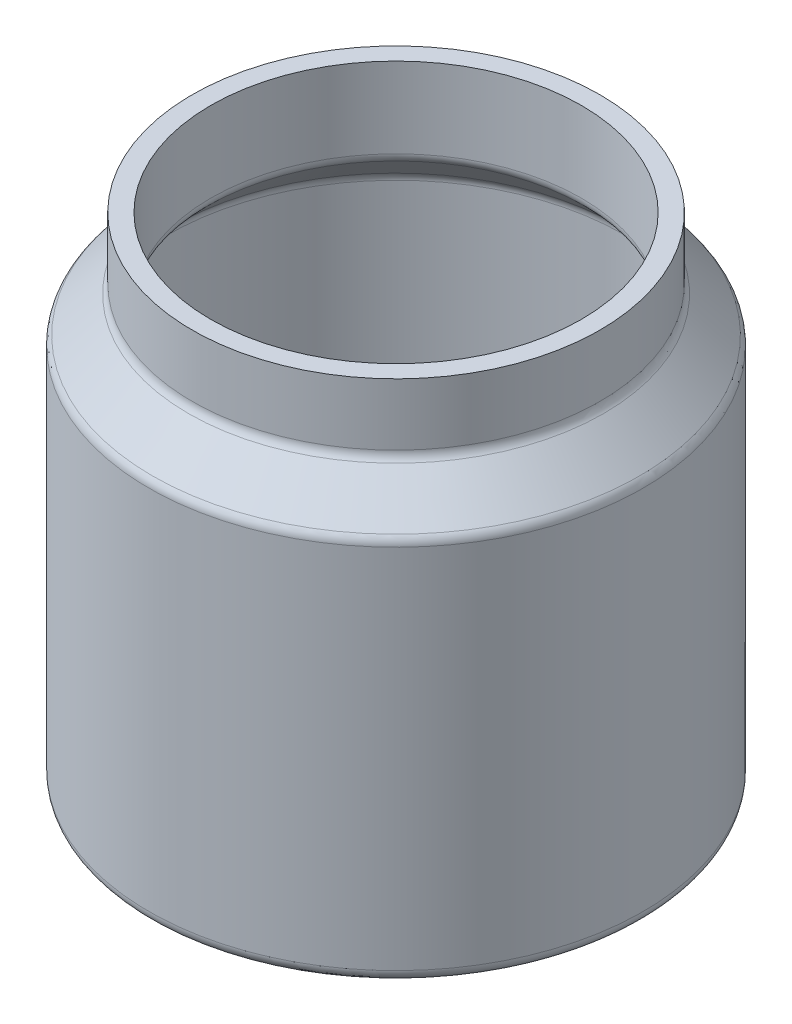
from build123d import *


with BuildPart() as part:
    # Esquisse1 → Révolution1 (revolve)
    with BuildSketch(Plane.XY):
        with BuildLine():
            Line((0, 0), (38, 0))
            ThreePointArc((38, 0), (39.414213562, 0.585786438), (40, 2))
            Line((40, 2), (40, 61.343145751))
            ThreePointArc((40, 61.343145751), (39.847759065, 62.108512615), (39.414213562, 62.757359313))
            Line((39.414213562, 62.757359313), (33.585786438, 68.585786438))
            ThreePointArc((33.585786438, 68.585786438), (33.152240935, 69.234633135), (33, 70))
            Line((33, 70), (33, 80))
            Line((33, 80), (30, 80))
            Line((30, 80), (30, 67))
            ThreePointArc((30, 67), (30.152240935, 66.234633135), (30.585786438, 65.585786438))
            Line((30.585786438, 65.585786438), (36.414213562, 59.757359313))
            ThreePointArc((36.414213562, 59.757359313), (36.847759065, 59.108512615), (37, 58.343145751))
            Line((37, 58.343145751), (37, 5))
            ThreePointArc((37, 5), (36.414213562, 3.585786438), (35, 3))
            Line((35, 3), (0, 3))
            Line((0, 3), (0, 0))
        make_face()
    revolve(axis=Axis((0, 0, 0), (0, 1, 0)))


solid = part.part
